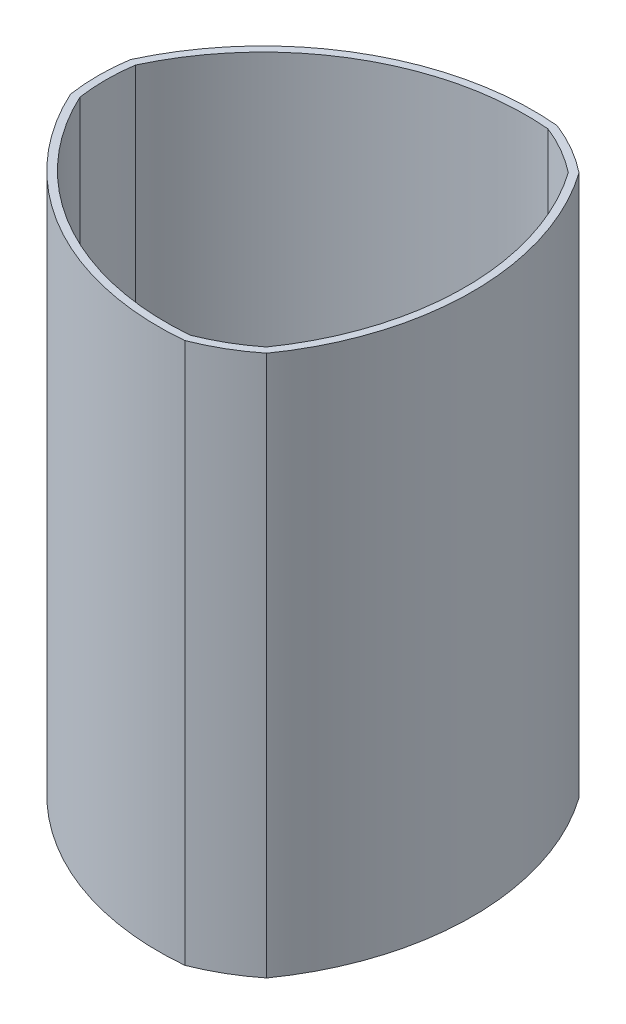
from build123d import *

# Parameters (mm, degrees)
SIDES_THE_GAP_VALUE_CAN_BE_CHANGED_DEPTH      = 228.6
BASE_DEPTH                                    = 3.175
SKETCH8_W                                     = 13.208
SKETCH8_H                                     = 1.524
SHOCK_CORD_CUTS_CAN_BE_MOVED_CURRENT_DI_DEPTH = 4.175


with BuildPart() as part:
    # Sketch3 → Sides (the gap value can be changed) (new body)
    with BuildSketch(Plane(origin=(0, 0, 0), x_dir=(1, 0, 0), z_dir=(0, 1, 0))):
        with BuildLine():
            ThreePointArc((-83.500112782, 12.664051105), (-84.455, 0), (-83.500112782, -12.664051105))
            ThreePointArc((-83.500112782, -12.664051105), (-36.842428798, -63.812958552), (30.782666419, -78.645244441))
            ThreePointArc((30.782666419, -78.645244441), (42.2275, -73.140175477), (52.717446363, -65.981193335))
            ThreePointArc((52.717446363, -65.981193335), (73.684857596, 0), (52.717446363, 65.981193335))
            ThreePointArc((52.717446363, 65.981193335), (42.2275, 73.140175477), (30.782666419, 78.645244441))
            ThreePointArc((30.782666419, 78.645244441), (-36.842428798, 63.812958552), (-83.500112782, 12.664051105))
        make_face()
        with BuildLine():
            ThreePointArc((50.384378709, 63.779720775), (70.509857596, 0), (50.384378709, -63.779720775))
            ThreePointArc((50.384378709, -63.779720775), (40.64, -70.39054482), (30.042669082, -75.524012303))
            ThreePointArc((30.042669082, -75.524012303), (-35.254928798, -61.063327895), (-80.427047792, -11.744291529))
            ThreePointArc((-80.427047792, -11.744291529), (-81.28, 0), (-80.427047792, 11.744291529))
            ThreePointArc((-80.427047792, 11.744291529), (-35.254928798, 61.063327895), (30.042669082, 75.524012303))
            ThreePointArc((30.042669082, 75.524012303), (40.64, 70.39054482), (50.384378709, 63.779720775))
        make_face(mode=Mode.SUBTRACT)
    extrude(amount=SIDES_THE_GAP_VALUE_CAN_BE_CHANGED_DEPTH)

    # Sketch7 → base (add)
    with BuildSketch(Plane(origin=(0, 0, 0), x_dir=(1, 0, 0), z_dir=(0, 1, 0))):
        with BuildLine():
            ThreePointArc((50.384378709, 63.779720775), (40.64, 70.39054482), (30.042669082, 75.524012303))
            ThreePointArc((30.042669082, 75.524012303), (-35.254928798, 61.063327895), (-80.427047792, 11.744291529))
            ThreePointArc((-80.427047792, 11.744291529), (-81.28, 0), (-80.427047792, -11.744291529))
            ThreePointArc((-80.427047792, -11.744291529), (-35.254928798, -61.063327895), (30.042669082, -75.524012303))
            ThreePointArc((30.042669082, -75.524012303), (40.64, -70.39054482), (50.384378709, -63.779720775))
            ThreePointArc((50.384378709, -63.779720775), (70.509857596, 0), (50.384378709, 63.779720775))
        make_face()
    extrude(amount=BASE_DEPTH)

    # Sketch8 → Shock cord cuts(Can be moved, current dim arbitrary) (cut, through all)
    with BuildSketch(Plane(origin=(0, 3.175, 0), x_dir=(1, 0, 0), z_dir=(0, 1, 0))):
        with Locations((0, 44.0055)):
            Rectangle(SKETCH8_W, SKETCH8_H)
        with Locations((0, -45.5295)):
            Rectangle(SKETCH8_W, SKETCH8_H)
    extrude(amount=-SHOCK_CORD_CUTS_CAN_BE_MOVED_CURRENT_DI_DEPTH, mode=Mode.SUBTRACT)


solid = part.part
